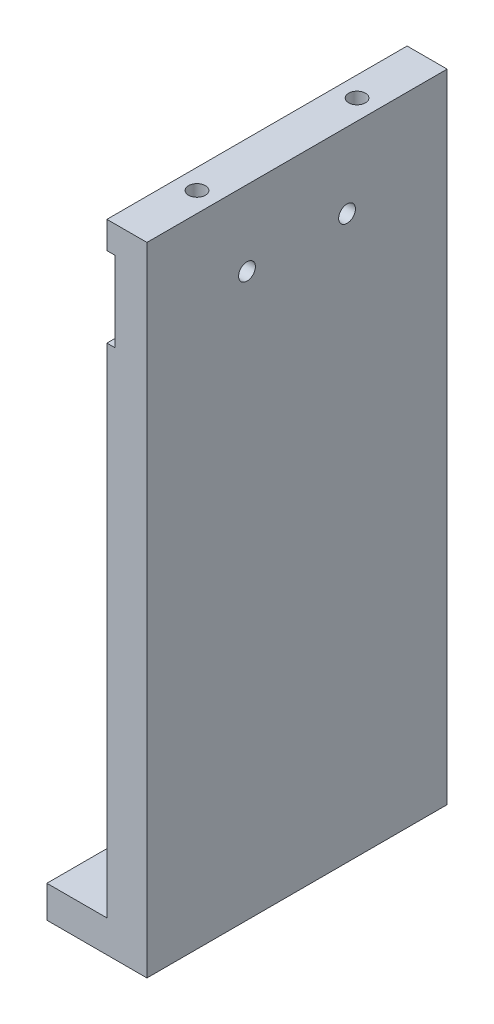
from build123d import *

# Parameters (mm, degrees)
SKETCH_1_W             = 10
SKETCH_1_H             = 159.15
EXTRUDE_1_DEPTH        = 75
HOLE_WIZARD_M5_1_D     = 4.2
HOLE_WIZARD_M5_1_DEPTH = 12.4
HOLE_WIZARD_M5_1_TIP   = 1.2618073
SKETCH_4_W             = 75
SKETCH_4_H             = 20
CUT_EXTRUDE_1_DEPTH    = 2
HOLE_WIZARD_M5_2_D     = 4.2
HOLE_WIZARD_M5_2_DEPTH = 12.4
HOLE_WIZARD_M5_2_TIP   = 1.2618073
SKETCH_7_W             = 75
SKETCH_7_H             = 8
EXTRUDE_2_DEPTH        = 15
SKETCH_8_R             = 3.25
CUT_EXTRUDE_2_DEPTH    = 9


with BuildPart() as part:
    # 草图1 → 凸台-拉伸1 (new body)
    with BuildSketch(Plane.XY):
        with Locations((5, 79.575)):
            Rectangle(SKETCH_1_W, SKETCH_1_H)
    extrude(amount=EXTRUDE_1_DEPTH)

    # M5 螺纹孔1
    with Locations(Plane(origin=(0, 159.15, 0), x_dir=(1, 0, 0), z_dir=(0, 1, 0))):
        with Locations((5, -57.5), (5, -17.5)):
            Hole(HOLE_WIZARD_M5_1_D / 2, depth=HOLE_WIZARD_M5_1_DEPTH)
            with Locations((0, 0, -(HOLE_WIZARD_M5_1_DEPTH + HOLE_WIZARD_M5_1_TIP / 2))):  # 118° drill point
                Cone(0, HOLE_WIZARD_M5_1_D / 2, HOLE_WIZARD_M5_1_TIP, mode=Mode.SUBTRACT)

    # 草图4 → 切除-拉伸1 (cut)
    with BuildSketch(Plane.ZY):
        with Locations((37.5, 142.38)):
            Rectangle(SKETCH_4_W, SKETCH_4_H)
    extrude(amount=-CUT_EXTRUDE_1_DEPTH, mode=Mode.SUBTRACT)

    # M5 螺纹孔2
    with Locations(Plane.ZY.offset(-2)):
        with Locations((25, 140.3817), (50, 140.3817)):
            Hole(HOLE_WIZARD_M5_2_D / 2, depth=HOLE_WIZARD_M5_2_DEPTH)
            with Locations((0, 0, -(HOLE_WIZARD_M5_2_DEPTH + HOLE_WIZARD_M5_2_TIP / 2))):  # 118° drill point
                Cone(0, HOLE_WIZARD_M5_2_D / 2, HOLE_WIZARD_M5_2_TIP, mode=Mode.SUBTRACT)

    # 草图7 → 凸台-拉伸2 (add)
    with BuildSketch(Plane.ZY):
        with Locations((37.5, 4)):
            Rectangle(SKETCH_7_W, SKETCH_7_H)
    extrude(amount=EXTRUDE_2_DEPTH)

    # 草图8 → 切除-拉伸2 (cut, through all)
    with BuildSketch(Plane(origin=(0, 8, 0), x_dir=(1, 0, 0), z_dir=(0, 1, 0))):
        with Locations((-7.5, -17.5)):
            Circle(SKETCH_8_R)
        with Locations((-7.5, -57.5)):
            Circle(SKETCH_8_R)
    extrude(amount=-CUT_EXTRUDE_2_DEPTH, mode=Mode.SUBTRACT)


solid = part.part
